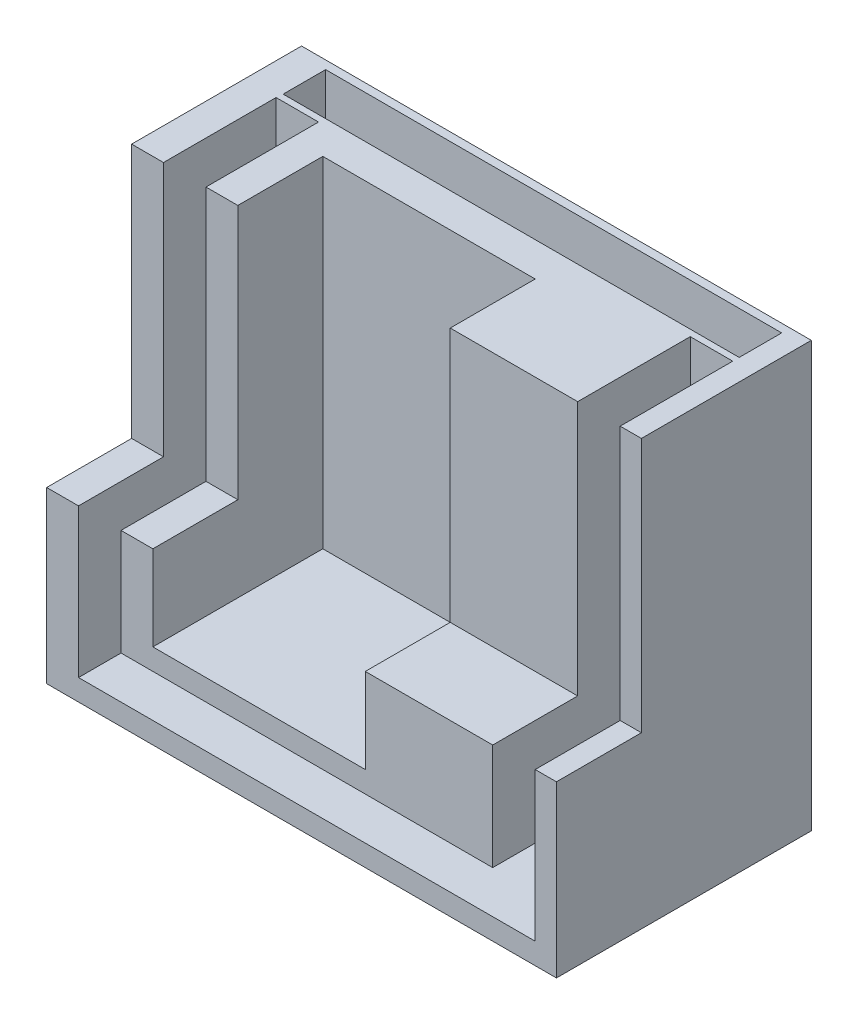
from build123d import *

# Parameters (mm, degrees)
BOSS_EXTRU_2_DEPTH       = 60
ESQUISSE2_W              = 5
ESQUISSE2_H              = 30
ESQUISSE2_H_2            = 20
ESQUISSE2_W_2            = 25
ENL_V_MAT_EXTRU_1_DEPTH  = 20
ESQUISSE4_W              = 60
ESQUISSE4_H              = 5
ENL_V_MAT_EXTRU_2_DEPTH  = 45
ESQUISSE5_W              = 56.25
ESQUISSE5_H              = 5
ESQUISSE5_W_2            = 3.75
ENL_V_MAT_EXTRU_4_DEPTH  = 27.5
ESQUISSE6_W              = 60
ESQUISSE6_H              = 2.5
BOSS_EXTRU_3_DEPTH       = 29.5
ESQUISSE7_W              = 3.75
ESQUISSE7_H              = 20
ESQUISSE7_W_2            = 13.75
BOSS_EXTRU_4_DEPTH       = 27.5
ESQUISSE8_W              = 3.75
ESQUISSE8_H              = 20
ESQUISSE8_W_2            = 13.75
BOSS_EXTRU_5_DEPTH       = 31.5
ESQUISSE10_W             = 42.5
ESQUISSE10_H             = 5
ENL_V_MAT_EXTRU_5_DEPTH  = 47.5
ESQUISSE11_W             = 5
ESQUISSE11_H             = 2.5
ESQUISSE11_W_2           = 3.75
ESQUISSE11_W_3           = 25
BOSS_EXTRU_6_DEPTH       = 20.5
ESQUISSE13_W             = 42.5
ESQUISSE13_H             = 5
ENL_V_MAT_EXTRU_7_DEPTH  = 27.5
ESQUISSE14_W             = 5
ESQUISSE14_H             = 10
ENL_V_MAT_EXTRU_8_DEPTH  = 40
ESQUISSE15_W             = 5
ESQUISSE15_H             = 20
BOSS_EXTRU_7_DEPTH       = 41
ESQUISSE16_W             = 5
ESQUISSE16_H             = 10
ENL_V_MAT_EXTRU_9_DEPTH  = 30
ESQUISSE17_W             = 5
ESQUISSE17_H             = 43.25
ENL_V_MAT_EXTRU_10_DEPTH = 23.25
ESQUISSE18_W             = 43.75
ESQUISSE18_H             = 0.75
BOSS_EXTRU_8_DEPTH       = 50
ESQUISSE19_W             = 48.75
ESQUISSE19_H             = 4.25
BOSS_EXTRU_9_DEPTH       = 50
ESQUISSE20_W             = 53.75
ESQUISSE20_H             = 5
ENL_V_MAT_EXTRU_11_DEPTH = 23
ESQUISSE21_W             = 53.677626311
ESQUISSE21_H             = 5
ENL_V_MAT_EXTRU_12_DEPTH = 48
ESQUISSE22_W             = 53.677626311
ESQUISSE22_H             = 5
BOSS_EXTRU_10_DEPTH      = 24


with BuildPart() as part:
    # Esquisse1 → Boss.-Extru.2 (new body)
    with BuildSketch(Plane(origin=(0, 0, 0), x_dir=(0, 0, -1), z_dir=(1, 0, 0))):
        Polygon((-38.339385634, 11.238718482), (-18.339385634, 11.238718482), (-18.339385634, -38.761281518), (-48.339385634, -38.761281518), (-48.339385634, -18.761281518), (-38.339385634, -18.761281518), align=None)
    extrude(amount=BOSS_EXTRU_2_DEPTH)

    # Esquisse2 → Enlèv. mat.-Extru.1 (cut)
    with BuildSketch(Plane.XY.offset(48.339385634)):
        with Locations((6.25, -3.761281518)):
            Rectangle(ESQUISSE2_W, ESQUISSE2_H)
        with Locations((6.25, -28.761281518)):
            Rectangle(ESQUISSE2_W, ESQUISSE2_H_2)
        with Locations((25, -3.761281518)):
            Rectangle(ESQUISSE2_W_2, ESQUISSE2_H)
        with Locations((25, -28.761281518)):
            Rectangle(ESQUISSE2_W_2, ESQUISSE2_H_2)
        with Locations((43.75, -3.761281518)):
            Rectangle(ESQUISSE2_W, ESQUISSE2_H)
        with Locations((43.75, -28.761281518)):
            Rectangle(ESQUISSE2_W, ESQUISSE2_H_2)
    extrude(amount=-ENL_V_MAT_EXTRU_1_DEPTH, mode=Mode.SUBTRACT)

    # Esquisse4 → Enlèv. mat.-Extru.2 (cut)
    with BuildSketch(Plane(origin=(0, 11.238718482, 0), x_dir=(1, 0, 0), z_dir=(0, 1, 0))):
        with Locations((30, -23.339385634)):
            Rectangle(ESQUISSE4_W, ESQUISSE4_H)
    extrude(amount=-ENL_V_MAT_EXTRU_2_DEPTH, mode=Mode.SUBTRACT)

    # Esquisse5 → Enlèv. mat.-Extru.4 (cut)
    with BuildSketch(Plane.XY.offset(48.339385634)):
        with Locations((31.875, -33.761281518)):
            Rectangle(ESQUISSE5_W, ESQUISSE5_H)
        with Locations((1.875, -33.761281518)):
            Rectangle(ESQUISSE5_W_2, ESQUISSE5_H)
    extrude(amount=-ENL_V_MAT_EXTRU_4_DEPTH, mode=Mode.SUBTRACT)

    # Esquisse6 → Boss.-Extru.3 (add)
    with BuildSketch(Plane.XY.offset(48.339385634)):
        with Locations((30, -37.511281518)):
            Rectangle(ESQUISSE6_W, ESQUISSE6_H)
    extrude(amount=-BOSS_EXTRU_3_DEPTH)

    # Esquisse7 → Boss.-Extru.4 (add)
    with BuildSketch(Plane.XY.offset(48.339385634)):
        with Locations((1.875, -28.761281518)):
            Rectangle(ESQUISSE7_W, ESQUISSE7_H)
        with Locations((10.625, -28.761281518)):
            Rectangle(ESQUISSE7_W, ESQUISSE7_H)
        with Locations((53.125, -28.761281518)):
            Rectangle(ESQUISSE7_W_2, ESQUISSE7_H)
        with Locations((39.375, -28.761281518)):
            Rectangle(ESQUISSE7_W, ESQUISSE7_H)
    extrude(amount=-BOSS_EXTRU_4_DEPTH)

    # Esquisse8 → Boss.-Extru.5 (add)
    with BuildSketch(Plane(origin=(0, 11.238718482, 0), x_dir=(1, 0, 0), z_dir=(0, 1, 0))):
        with Locations((1.875, -28.339385634)):
            Rectangle(ESQUISSE8_W, ESQUISSE8_H)
        with Locations((10.625, -28.339385634)):
            Rectangle(ESQUISSE8_W, ESQUISSE8_H)
        with Locations((53.125, -28.339385634)):
            Rectangle(ESQUISSE8_W_2, ESQUISSE8_H)
        with Locations((39.375, -28.339385634)):
            Rectangle(ESQUISSE8_W, ESQUISSE8_H)
    extrude(amount=-BOSS_EXTRU_5_DEPTH)

    # Esquisse10 → Enlèv. mat.-Extru.5 (cut)
    with BuildSketch(Plane(origin=(0, 11.238718482, 0), x_dir=(1, 0, 0), z_dir=(0, 1, 0))):
        with Locations((25, -23.339385634)):
            Rectangle(ESQUISSE10_W, ESQUISSE10_H)
    extrude(amount=-ENL_V_MAT_EXTRU_5_DEPTH, mode=Mode.SUBTRACT)

    # Esquisse11 → Boss.-Extru.6 (add)
    with BuildSketch(Plane.XY.offset(48.339385634)):
        with Locations((43.75, -30.011281518)):
            Rectangle(ESQUISSE11_W, ESQUISSE11_H)
        with Locations((39.375, -30.011281518)):
            Rectangle(ESQUISSE11_W_2, ESQUISSE11_H)
        with Locations((25, -30.011281518)):
            Rectangle(ESQUISSE11_W_3, ESQUISSE11_H)
        with Locations((6.25, -30.011281518)):
            Rectangle(ESQUISSE11_W, ESQUISSE11_H)
        with Locations((10.625, -30.011281518)):
            Rectangle(ESQUISSE11_W_2, ESQUISSE11_H)
    extrude(amount=-BOSS_EXTRU_6_DEPTH)

    # Esquisse13 → Enlèv. mat.-Extru.7 (cut)
    with BuildSketch(Plane.XY.offset(48.339385634)):
        with Locations((25, -33.761281518)):
            Rectangle(ESQUISSE13_W, ESQUISSE13_H)
    extrude(amount=-ENL_V_MAT_EXTRU_7_DEPTH, mode=Mode.SUBTRACT)

    # Esquisse14 → Enlèv. mat.-Extru.8 (cut)
    with BuildSketch(Plane(origin=(0, 11.238718482, 0), x_dir=(1, 0, 0), z_dir=(0, 1, 0))):
        with Locations((55, -33.339385634)):
            Rectangle(ESQUISSE14_W, ESQUISSE14_H)
        with Locations((55, -43.339385634)):
            Rectangle(ESQUISSE14_W, ESQUISSE14_H)
    extrude(amount=-ENL_V_MAT_EXTRU_8_DEPTH, mode=Mode.SUBTRACT)

    # Esquisse15 → Boss.-Extru.7 (add)
    with BuildSketch(Plane(origin=(0, 11.238718482, 0), x_dir=(1, 0, 0), z_dir=(0, 1, 0))):
        with Locations((43.75, -38.339385634)):
            Rectangle(ESQUISSE15_W, ESQUISSE15_H)
    extrude(amount=-BOSS_EXTRU_7_DEPTH)

    # Esquisse16 → Enlèv. mat.-Extru.9 (cut)
    with BuildSketch(Plane(origin=(0, 11.238718482, 0), x_dir=(1, 0, 0), z_dir=(0, 1, 0))):
        with Locations((43.75, -43.339385634)):
            Rectangle(ESQUISSE16_W, ESQUISSE16_H)
    extrude(amount=-ENL_V_MAT_EXTRU_9_DEPTH, mode=Mode.SUBTRACT)

    # Esquisse17 → Enlèv. mat.-Extru.10 (cut)
    with BuildSketch(Plane.XY.offset(48.339385634)):
        with Locations((55, -10.386281518)):
            Rectangle(ESQUISSE17_W, ESQUISSE17_H)
        with Locations((6.25, -10.386281518)):
            Rectangle(ESQUISSE17_W, ESQUISSE17_H)
    extrude(amount=-ENL_V_MAT_EXTRU_10_DEPTH, mode=Mode.SUBTRACT)

    # Esquisse18 → Boss.-Extru.8 (add)
    with BuildSketch(Plane(origin=(0, 11.238718482, 0), x_dir=(1, 0, 0), z_dir=(0, 1, 0))):
        with Locations((30.625, -25.464385634)):
            Rectangle(ESQUISSE18_W, ESQUISSE18_H)
    extrude(amount=-BOSS_EXTRU_8_DEPTH)

    # Esquisse19 → Boss.-Extru.9 (add)
    with BuildSketch(Plane(origin=(0, 11.238718482, 0), x_dir=(1, 0, 0), z_dir=(0, 1, 0))):
        with Locations((28.125, -22.964385634)):
            Rectangle(ESQUISSE19_W, ESQUISSE19_H)
    extrude(amount=-BOSS_EXTRU_9_DEPTH)

    # Esquisse20 → Enlèv. mat.-Extru.11 (cut)
    with BuildSketch(Plane.XY.offset(48.339385634)):
        with Locations((30.625, -33.761281518)):
            Rectangle(ESQUISSE20_W, ESQUISSE20_H)
    extrude(amount=-ENL_V_MAT_EXTRU_11_DEPTH, mode=Mode.SUBTRACT)

    # Esquisse21 → Enlèv. mat.-Extru.12 (cut)
    with BuildSketch(Plane(origin=(0, 11.238718482, 0), x_dir=(1, 0, 0), z_dir=(0, 1, 0))):
        with Locations((30.661186845, -21.828072333)):
            Rectangle(ESQUISSE21_W, ESQUISSE21_H)
    extrude(amount=-ENL_V_MAT_EXTRU_12_DEPTH, mode=Mode.SUBTRACT)

    # Esquisse22 → Boss.-Extru.10 (add)
    with BuildSketch(Plane(origin=(0, -36.761281518, 0), x_dir=(1, 0, 0), z_dir=(0, 1, 0))):
        with Locations((30.661186845, -21.828072333)):
            Rectangle(ESQUISSE22_W, ESQUISSE22_H)
    extrude(amount=BOSS_EXTRU_10_DEPTH)


solid = part.part
